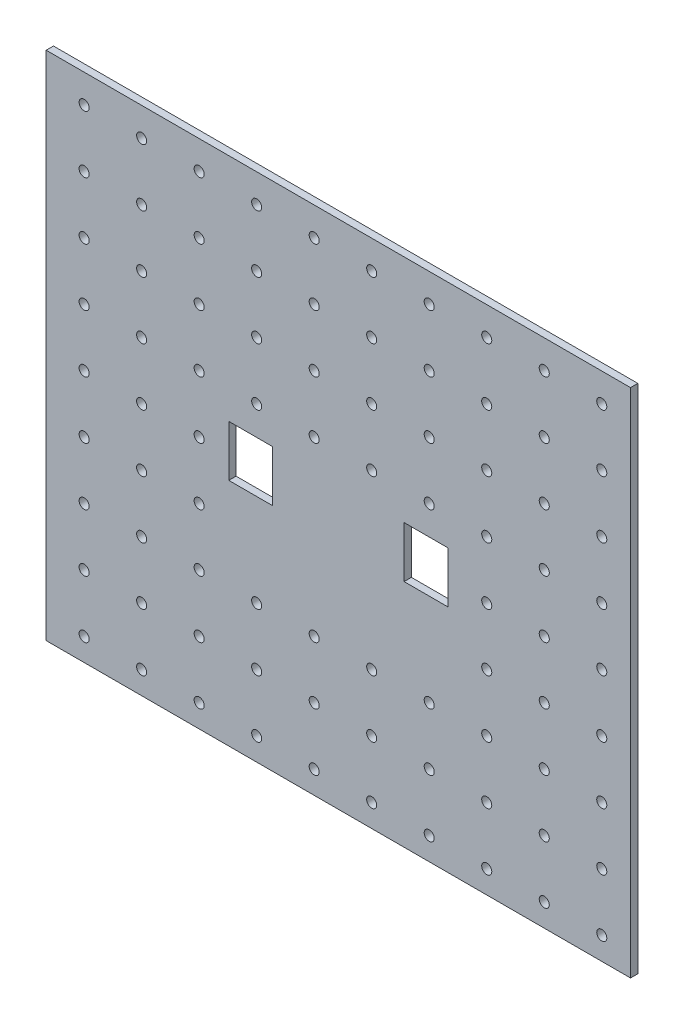
from build123d import *

# Parameters (mm, degrees)
SKETCH1_W            = 203.2
SKETCH1_H            = 177.8
SKETCH1_W_2          = 15.24
SKETCH1_H_2          = 17.78
BOSS_EXTRUDE1_DEPTH  = 2.54
LPATTERN2_COUNT      = 9
LPATTERN2_PITCH      = 20
LPATTERN2_COUNT_DIR2 = 10
LPATTERN2_PITCH_DIR2 = 20


with BuildPart() as part:
    # Sketch1 → Boss-Extrude1 (new body)
    with BuildSketch(Plane.XY):
        Rectangle(SKETCH1_W, SKETCH1_H)
        with Locations((-30.48, 0)):
            Rectangle(SKETCH1_W_2, SKETCH1_H_2, mode=Mode.SUBTRACT)
        with Locations((30.48, 0)):
            Rectangle(SKETCH1_W_2, SKETCH1_H_2, mode=Mode.SUBTRACT)
    extrude(amount=BOSS_EXTRUDE1_DEPTH)

    # Sketch4 → M2.5 Clearance Hole1 (revolve, cut)
    with BuildSketch(Plane(origin=(91.6, 78.994, 0), x_dir=(0, 1, 0), z_dir=(1, 0, 0))):
        Polygon((0, 0), (0, 5.623506083), (1.75, 4.572), (1.75, 0), align=None)
    m2_5_clearance_hole1 = revolve(axis=Axis((91.6, 78.994, -6.35), (0, 0, 1)), mode=Mode.SUBTRACT)

    # LPattern2: M2.5 Clearance Hole1 9 × 10, 8 skipped
    with Locations(*[(-j * LPATTERN2_PITCH_DIR2, -i * LPATTERN2_PITCH, 0) for i in range(LPATTERN2_COUNT) for j in range(LPATTERN2_COUNT_DIR2) if (i, j) not in ((0, 0), (4, 3), (4, 4), (4, 5), (4, 6), (5, 3), (5, 4), (5, 5), (5, 6))]):
        add(m2_5_clearance_hole1, mode=Mode.SUBTRACT)


solid = part.part
